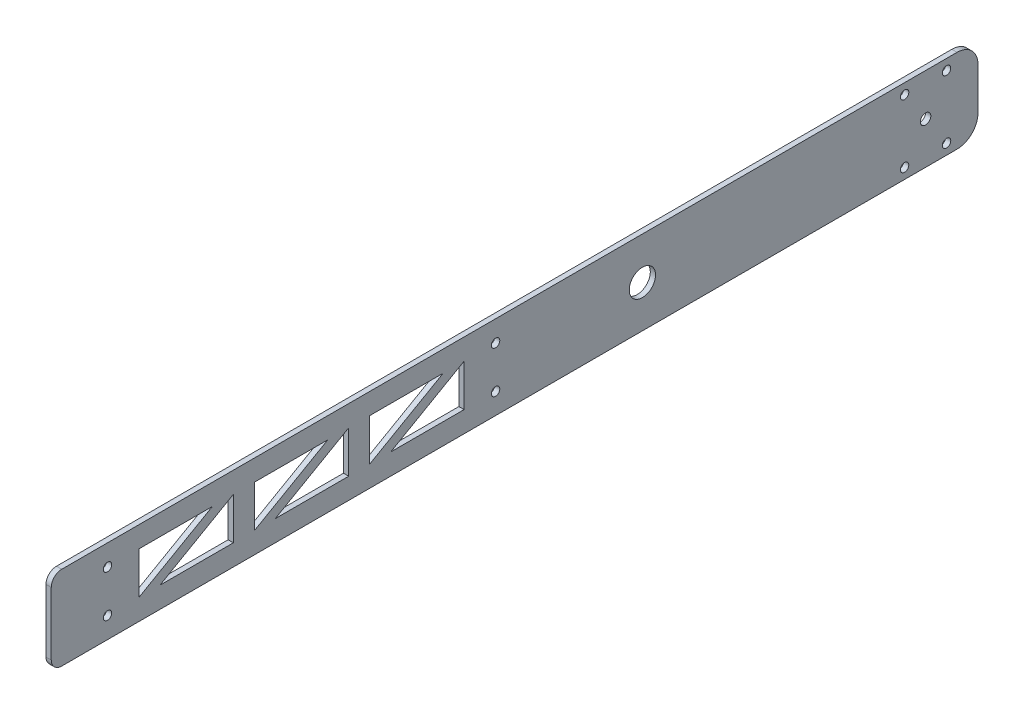
from build123d import *

# Parameters (mm, degrees)
SKETCH1_R           = 7.9629
SKETCH1_R_2         = 3.175
SKETCH1_R_3         = 2.5527
BOSS_EXTRUDE1_DEPTH = 3.175
SKETCH2_R           = 5.55625
CUT_EXTRUDE1_DEPTH  = 4.175
SKETCH3_W           = 200.88
SKETCH3_H           = 50.8
CUT_EXTRUDE2_DEPTH  = 4.175
FILLET1_R           = 6.35


with BuildPart() as part:
    # Sketch1 → Boss-Extrude1 (new body)
    with BuildSketch(Plane(origin=(0, 0, 0), x_dir=(0, 0, -1), z_dir=(1, 0, 0))):
        with BuildLine():
            Line((177.8, 38.1), (177.8, 12.7))
            ThreePointArc((177.8, 12.7), (174.080256121, 3.719743879), (165.1, 0))
            Line((165.1, 0), (-571.5, 0))
            ThreePointArc((-571.5, 0), (-580.480256121, 3.719743879), (-584.2, 12.7))
            Line((-584.2, 12.7), (-584.2, 38.1))
            ThreePointArc((-584.2, 38.1), (-580.480256121, 47.080256121), (-571.5, 50.8))
            Line((-571.5, 50.8), (165.1, 50.8))
            ThreePointArc((165.1, 50.8), (174.080256121, 47.080256121), (177.8, 38.1))
        make_face()
        with Locations((-25.4, 25.4)):
            Circle(SKETCH1_R, mode=Mode.SUBTRACT)
        with Locations((146.05, 25.4)):
            Circle(SKETCH1_R_2, mode=Mode.SUBTRACT)
        with Locations((-349.25, 38.1)):
            Circle(SKETCH1_R_3, mode=Mode.SUBTRACT)
        with Locations((-349.25, 12.7)):
            Circle(SKETCH1_R_3, mode=Mode.SUBTRACT)
        with Locations((-114.3, 38.1)):
            Circle(SKETCH1_R_3, mode=Mode.SUBTRACT)
        with Locations((-114.3, 12.7)):
            Circle(SKETCH1_R_3, mode=Mode.SUBTRACT)
        with Locations((133.35, 44.45)):
            Circle(SKETCH1_R_3, mode=Mode.SUBTRACT)
        with Locations((158.75, 44.45)):
            Circle(SKETCH1_R_3, mode=Mode.SUBTRACT)
        with Locations((158.75, 6.35)):
            Circle(SKETCH1_R_3, mode=Mode.SUBTRACT)
        with Locations((133.35, 6.35)):
            Circle(SKETCH1_R_3, mode=Mode.SUBTRACT)
        Polygon((-190.5, 38.1), (-146.05, 38.1), (-190.5, 12.7), align=None, mode=Mode.SUBTRACT)
        Polygon((-133.35, 38.1), (-133.35, 12.7), (-177.8, 12.7), align=None, mode=Mode.SUBTRACT)
        Polygon((-203.2, 12.7), (-203.2, 38.1), (-247.65, 12.7), align=None, mode=Mode.SUBTRACT)
        Polygon((-215.9, 38.1), (-260.35, 12.7), (-260.35, 38.1), align=None, mode=Mode.SUBTRACT)
        Polygon((-273.05, 38.1), (-273.05, 12.7), (-317.5, 12.7), align=None, mode=Mode.SUBTRACT)
        Polygon((-330.2, 12.7), (-330.2, 38.1), (-285.75, 38.1), align=None, mode=Mode.SUBTRACT)
    extrude(amount=BOSS_EXTRUDE1_DEPTH)

    # Sketch2 → Cut-Extrude1 (cut, through all)
    with BuildSketch(Plane(origin=(3.175, 0, 0), x_dir=(0, 0, -1), z_dir=(1, 0, 0))):
        with Locations((-558.8, 25.4)):
            Circle(SKETCH2_R)
    extrude(amount=-CUT_EXTRUDE1_DEPTH, mode=Mode.SUBTRACT)

    # Sketch3 → Cut-Extrude2 (cut, through all)
    with BuildSketch(Plane(origin=(3.175, 0, 0), x_dir=(0, 0, -1), z_dir=(1, 0, 0))):
        with Locations((-483.76, 25.4)):
            Rectangle(SKETCH3_W, SKETCH3_H)
    extrude(amount=-CUT_EXTRUDE2_DEPTH, mode=Mode.SUBTRACT)

    # Fillet1
    fillet1_edges = [part.edges().sort_by_distance(p)[0] for p in [
        (1.5875, 0, 383.32),
        (1.5875, 50.8, 383.32),
    ]]
    fillet(fillet1_edges, radius=FILLET1_R)


solid = part.part
